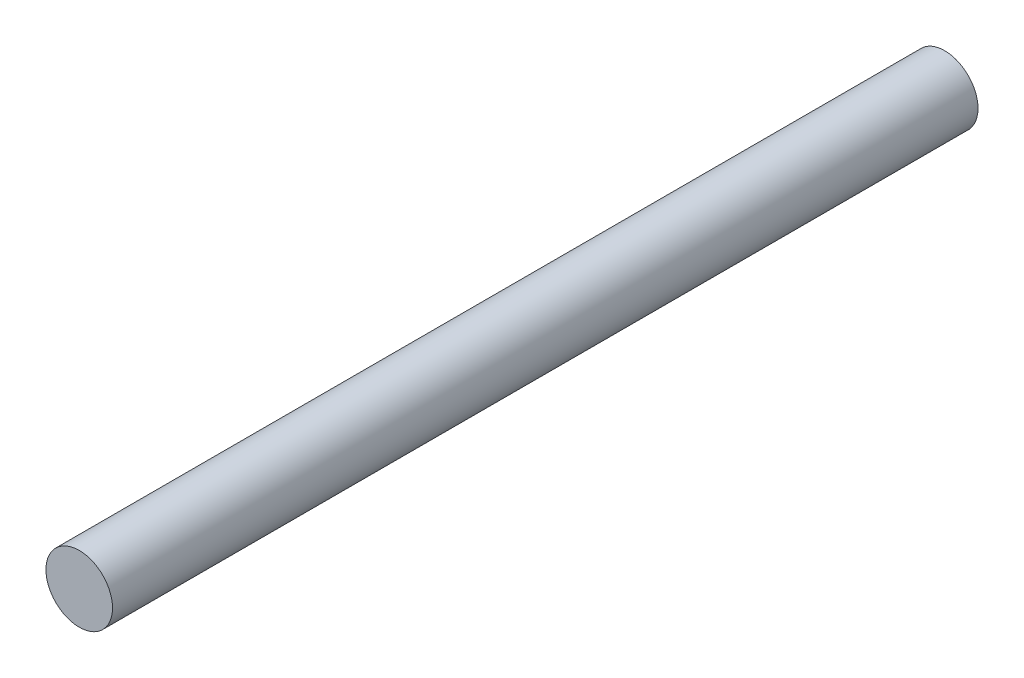
from build123d import *

# Parameters (mm, degrees)
SKETCH1_R           = 5
BOSS_EXTRUDE1_DEPTH = 130


with BuildPart() as part:
    # Sketch1 → Boss-Extrude1 (new body)
    with BuildSketch(Plane.XY):
        Circle(SKETCH1_R)
    extrude(amount=BOSS_EXTRUDE1_DEPTH)


solid = part.part
